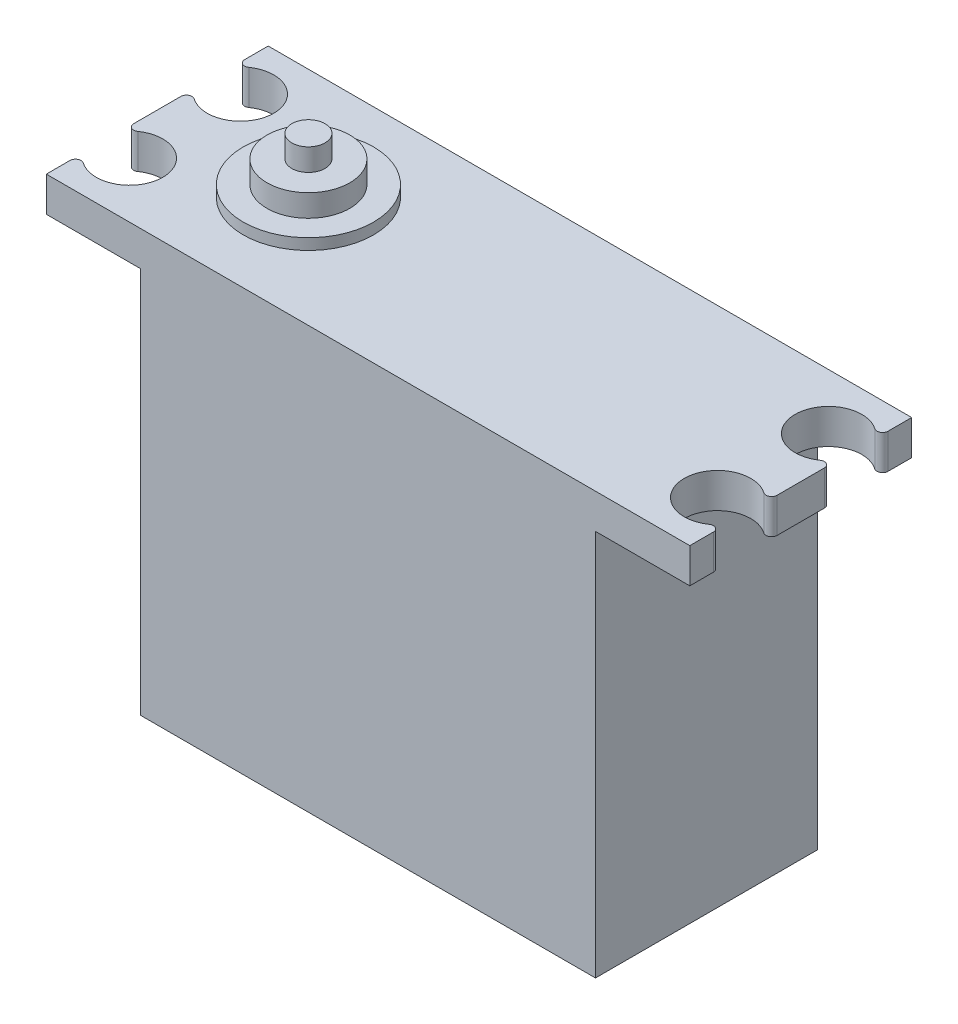
from build123d import *

# Parameters (mm, degrees)
BOSS_EXTRUDE1_DEPTH = 20
SKETCH2_R           = 3
CUT_EXTRUDE2_DEPTH  = 39
FILLET1_R           = 0.5
SKETCH4_R           = 5.872078672
BOSS_EXTRUDE2_DEPTH = 1
SKETCH5_R           = 3.732814836
BOSS_EXTRUDE3_DEPTH = 2
SKETCH8_R           = 1.5
BOSS_EXTRUDE4_DEPTH = 2


with BuildPart() as part:
    # Sketch1 → Boss-Extrude1 (new body)
    with BuildSketch(Plane.XY):
        Polygon((-29, 19), (29, 19), (29, 15.862733035), (20.5, 15.862733035), (20.5, -19), (-20.5, -19), (-20.5, 15.862733035), (-29, 15.862733035), align=None)
    extrude(amount=-BOSS_EXTRUDE1_DEPTH)

    # Sketch2 → Cut-Extrude2 (cut, through all)
    with BuildSketch(Plane(origin=(0, 19, 0), x_dir=(1, 0, 0), z_dir=(0, 1, 0))):
        with Locations((26.5, 5)):
            Circle(SKETCH2_R)
        with Locations((26.5, 15)):
            Circle(SKETCH2_R)
        with Locations((-26.5, 5)):
            Circle(SKETCH2_R)
        with Locations((-26.5, 15)):
            Circle(SKETCH2_R)
    extrude(amount=-CUT_EXTRUDE2_DEPTH, mode=Mode.SUBTRACT)

    # Fillet1
    fillet1_edges = [part.edges().sort_by_distance(p)[0] for p in [
        (29, 17.431366518, -3.341687605),
        (29, 17.431366518, -6.658312395),
        (29, 17.431366518, -13.341687605),
        (29, 17.431366518, -16.658312395),
        (-29, 17.431366518, -3.341687605),
        (-29, 17.431366518, -6.658312395),
        (-29, 17.431366518, -13.341687605),
        (-29, 17.431366518, -16.658312395),
    ]]
    fillet(fillet1_edges, radius=FILLET1_R)

    # Sketch4 → Boss-Extrude2 (add)
    with BuildSketch(Plane(origin=(0, 19, 0), x_dir=(1, 0, 0), z_dir=(0, 1, 0))):
        with Locations((-15.375793184, 10)):
            Circle(SKETCH4_R)
    extrude(amount=BOSS_EXTRUDE2_DEPTH)

    # Sketch5 → Boss-Extrude3 (add)
    with BuildSketch(Plane(origin=(0, 20, 0), x_dir=(1, 0, 0), z_dir=(0, 1, 0))):
        with Locations((-15.375793184, 10)):
            Circle(SKETCH5_R)
    extrude(amount=BOSS_EXTRUDE3_DEPTH)

    # Sketch8 → Boss-Extrude4 (add)
    with BuildSketch(Plane(origin=(0, 22, 0), x_dir=(1, 0, 0), z_dir=(0, 1, 0))):
        with Locations((-15.375793184, 10)):
            Circle(SKETCH8_R)
    extrude(amount=BOSS_EXTRUDE4_DEPTH)


solid = part.part
